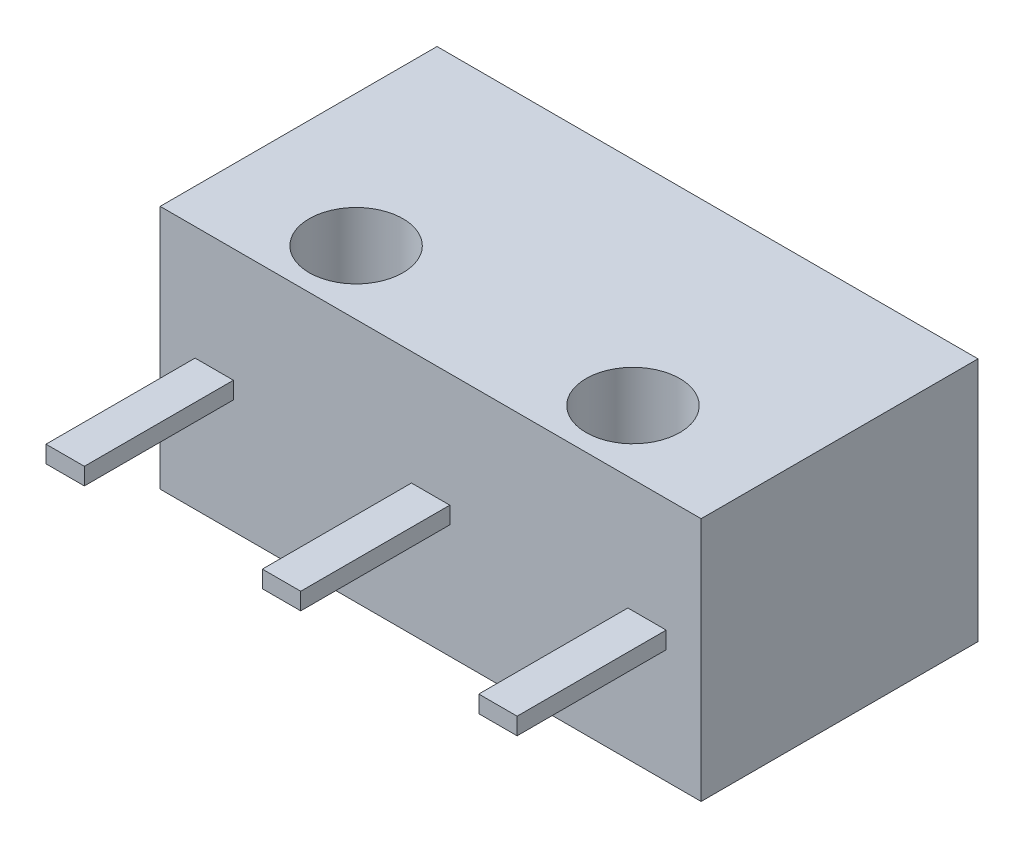
from build123d import *

# Parameters (mm, degrees)
SKETCH1_W                = 12.7
SKETCH1_H                = 6.5
BOSS_EXTRUDE1_DEPTH      = 5.75
SKETCH2_R                = 1.1
CUT_EXTRUDE1_DEPTH       = 6.75
SKETCH3_W                = 0.9
SKETCH3_H                = 3.5
BOSS_EXTRUDE2_DEPTH      = 0.2
BOSS_EXTRUDE2_DEPTH_BACK = 0.2
BOSS_EXTRUDE3_DEPTH      = 1.45
BOSS_EXTRUDE3_DEPTH_BACK = 1.45


with BuildPart() as part:
    # Sketch1 → Boss-Extrude1 (new body)
    with BuildSketch(Plane(origin=(0, 0, 0), x_dir=(1, 0, 0), z_dir=(0, 1, 0))):
        with Locations((6.35, 3.25)):
            Rectangle(SKETCH1_W, SKETCH1_H)
    extrude(amount=BOSS_EXTRUDE1_DEPTH)

    # Sketch2 → Cut-Extrude1 (cut, through all)
    with BuildSketch(Plane(origin=(0, 5.75, 0), x_dir=(1, 0, 0), z_dir=(0, 1, 0))):
        with Locations((3.1, 1.5)):
            Circle(SKETCH2_R)
        with Locations((9.6, 1.5)):
            Circle(SKETCH2_R)
    extrude(amount=-CUT_EXTRUDE1_DEPTH, mode=Mode.SUBTRACT)

    # Sketch3 → Boss-Extrude2 (add, two sides)
    with BuildSketch(Plane(origin=(0, 2.875, 0), x_dir=(1, 0, 0), z_dir=(0, 1, 0))) as boss_extrude2_sk:
        with Locations((6.35, -1.75)):
            Rectangle(SKETCH3_W, SKETCH3_H)
        Polygon((11.88, 0), (11.88, -3.5), (11.43, -3.5), (10.98, -3.5), (10.98, 0), align=None)
        Polygon((0.82, 0), (1.72, 0), (1.72, -3.5), (1.27, -3.5), (0.82, -3.5), align=None)
    extrude(amount=BOSS_EXTRUDE2_DEPTH)
    extrude(boss_extrude2_sk.sketch, amount=-BOSS_EXTRUDE2_DEPTH_BACK)

    # Sketch4 → Boss-Extrude3 (add, two sides)
    with BuildSketch(Plane(origin=(0, 2.875, 0), x_dir=(1, 0, 0), z_dir=(0, 1, 0))) as boss_extrude3_sk:
        with BuildLine():
            Line((3.8, 6.5), (5, 6.5))
            ThreePointArc((5, 6.5), (4.4, 7.1), (3.8, 6.5))
        make_face()
    extrude(amount=BOSS_EXTRUDE3_DEPTH)
    extrude(boss_extrude3_sk.sketch, amount=-BOSS_EXTRUDE3_DEPTH_BACK)


solid = part.part
